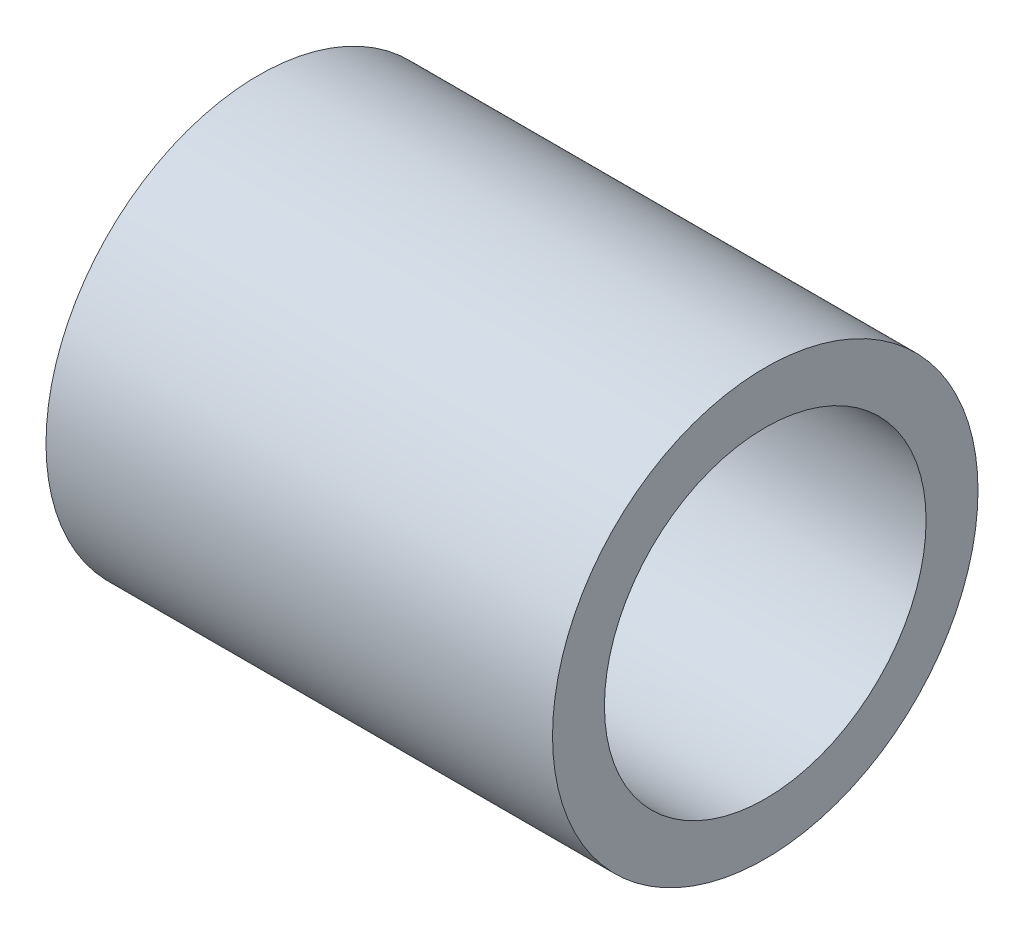
from build123d import *

# Parameters (mm, degrees)
SKETCH1_R           = 2.1
SKETCH1_R_2         = 1.5875
BOSS_EXTRUDE1_DEPTH = 2.5


with BuildPart() as part:
    # Sketch1 → Boss-Extrude1 (new body, symmetric)
    with BuildSketch(Plane(origin=(0, 0, 0), x_dir=(0, 0, -1), z_dir=(1, 0, 0))):
        Circle(SKETCH1_R)
        Circle(SKETCH1_R_2, mode=Mode.SUBTRACT)
    extrude(amount=BOSS_EXTRUDE1_DEPTH, both=True)


solid = part.part
